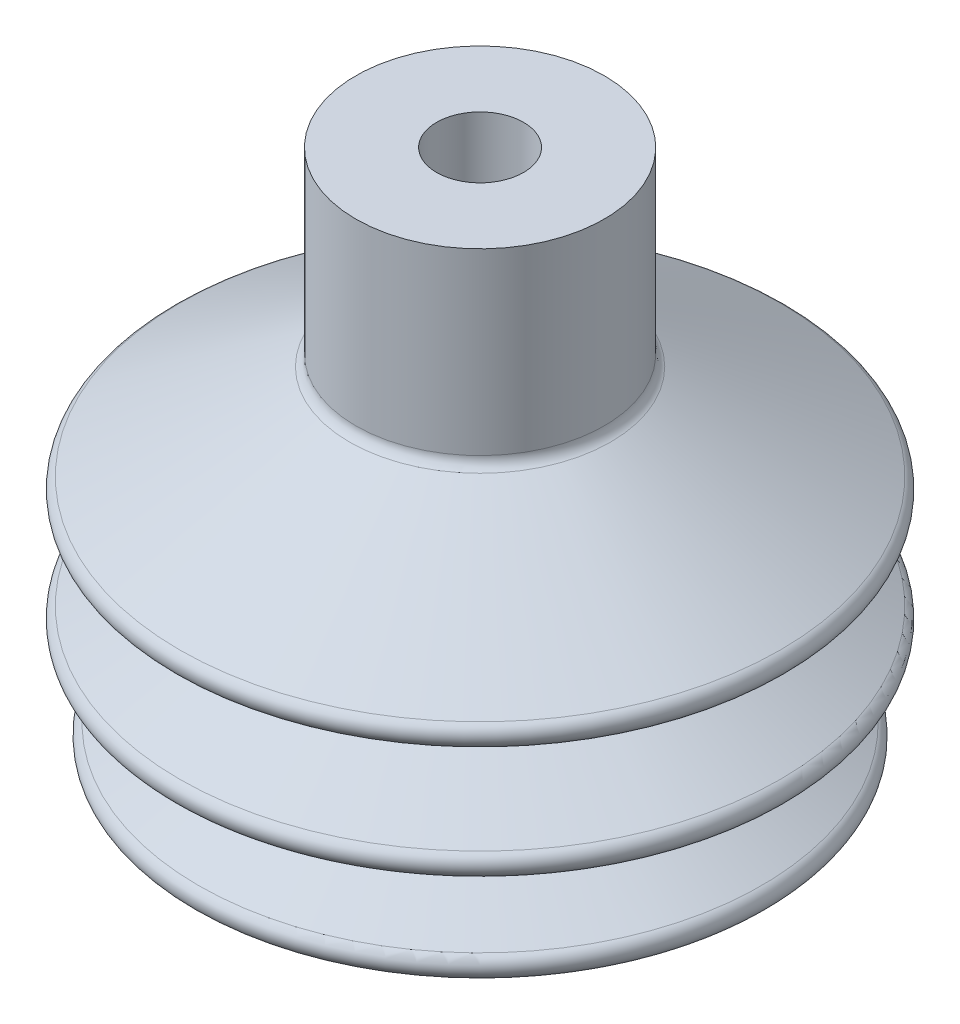
from build123d import *

# Parameters (mm, degrees)
SKETCH_1_R      = 10
SKETCH_1_R_2    = 3.5
EXTRUDE_1_DEPTH = 15
FILLET_1_R      = 1


with BuildPart() as part:
    # 草图1 → 凸台-拉伸1 (new body)
    with BuildSketch(Plane(origin=(0, 0, 0), x_dir=(1, 0, 0), z_dir=(0, 1, 0))):
        Circle(SKETCH_1_R)
        Circle(SKETCH_1_R_2, mode=Mode.SUBTRACT)
    extrude(amount=EXTRUDE_1_DEPTH)

    # 草图3 → 旋转1 (revolve)
    with BuildSketch(Plane.XY):
        Polygon((10, 0), (26, -8.966068261), (16.62454313, -12.729222488), (26, -17.98303413), (16.62454313, -21.746188358), (26, -27), (21.908809158, -27), (12, -21.447308794), (21.37545687, -17.684154567), (12, -12.430342924), (21.37545687, -8.667188697), (5.908809158, 0), align=None)
    revolve(axis=Axis((0, 0, 0), (0, 1, 0)))

    # 圆角1
    fillet_1_edges = [part.edges().sort_by_distance(p)[0] for p in [
        (-10, 0, 0),
        (-26, -8.966068261, 0),
        (-26, -17.98303413, 0),
        (-26, -27, 0),
    ]]
    fillet(fillet_1_edges, radius=FILLET_1_R)


solid = part.part
